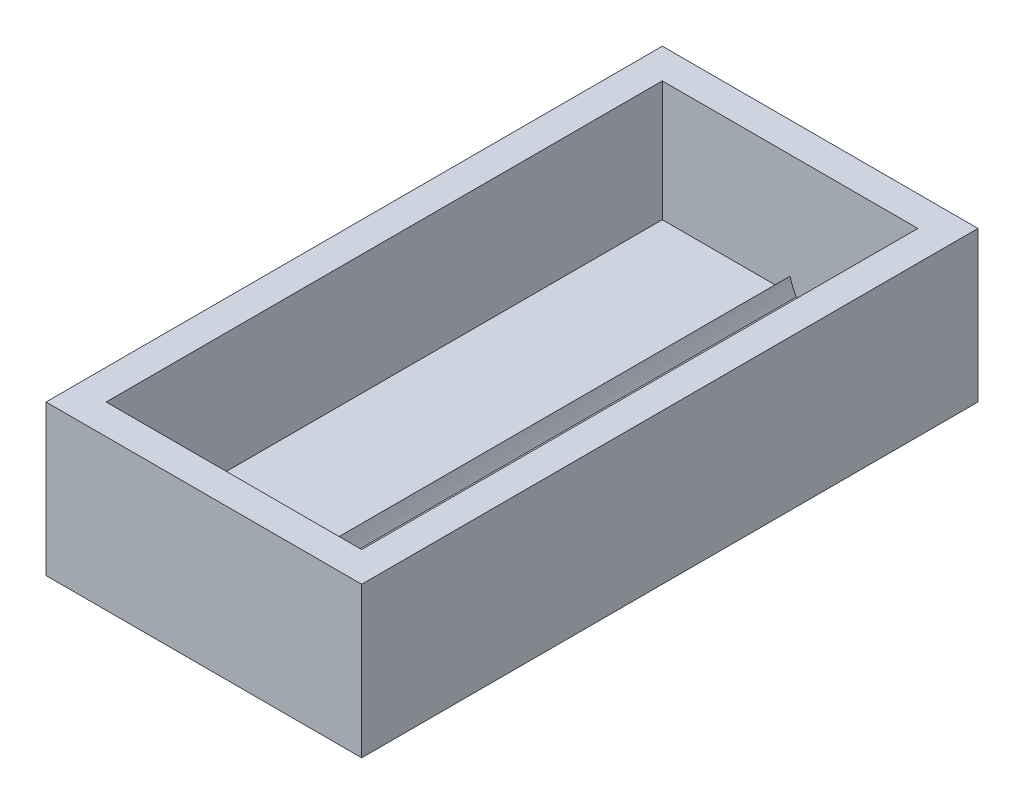
from build123d import *

# Parameters (mm, degrees)
SKETCH1_W           = 26.67
SKETCH1_H           = 52.07
BOSS_EXTRUDE1_DEPTH = 12.7
SKETCH2_W           = 21.59
SKETCH2_H           = 46.99
CUT_EXTRUDE1_DEPTH  = 10.16
BOSS_EXTRUDE2_REACH = 54.07


with BuildPart() as part:
    # Sketch1 → Boss-Extrude1 (new body)
    with BuildSketch(Plane(origin=(0, 0, 0), x_dir=(1, 0, 0), z_dir=(0, 1, 0))):
        with Locations((13.335, 26.035)):
            Rectangle(SKETCH1_W, SKETCH1_H)
    extrude(amount=BOSS_EXTRUDE1_DEPTH)

    # Sketch2 → Cut-Extrude1 (cut)
    with BuildSketch(Plane(origin=(0, 12.7, 0), x_dir=(1, 0, 0), z_dir=(0, 1, 0))):
        with Locations((13.335, 26.035)):
            Rectangle(SKETCH2_W, SKETCH2_H)
    extrude(amount=-CUT_EXTRUDE1_DEPTH, mode=Mode.SUBTRACT)

    # Sketch4 → Boss-Extrude2 (add, up to next)
    with BuildSketch(Plane.XY, mode=Mode.PRIVATE) as boss_extrude2_sk1:
        with BuildLine():
            Line((8.89, 0), (17.78, 0))
            ThreePointArc((17.78, 0), (14.953468796, 1.200296929), (13.335, 3.81))
            ThreePointArc((13.335, 3.81), (11.716531204, 1.200296929), (8.89, 0))
        make_face()
    boss_extrude2_tool1 = extrude(boss_extrude2_sk1.sketch, amount=-BOSS_EXTRUDE2_REACH, mode=Mode.PRIVATE) - part.part
    add(boss_extrude2_tool1.solids().sort_by_distance((13.335, 0.99851, 0))[0])


solid = part.part
